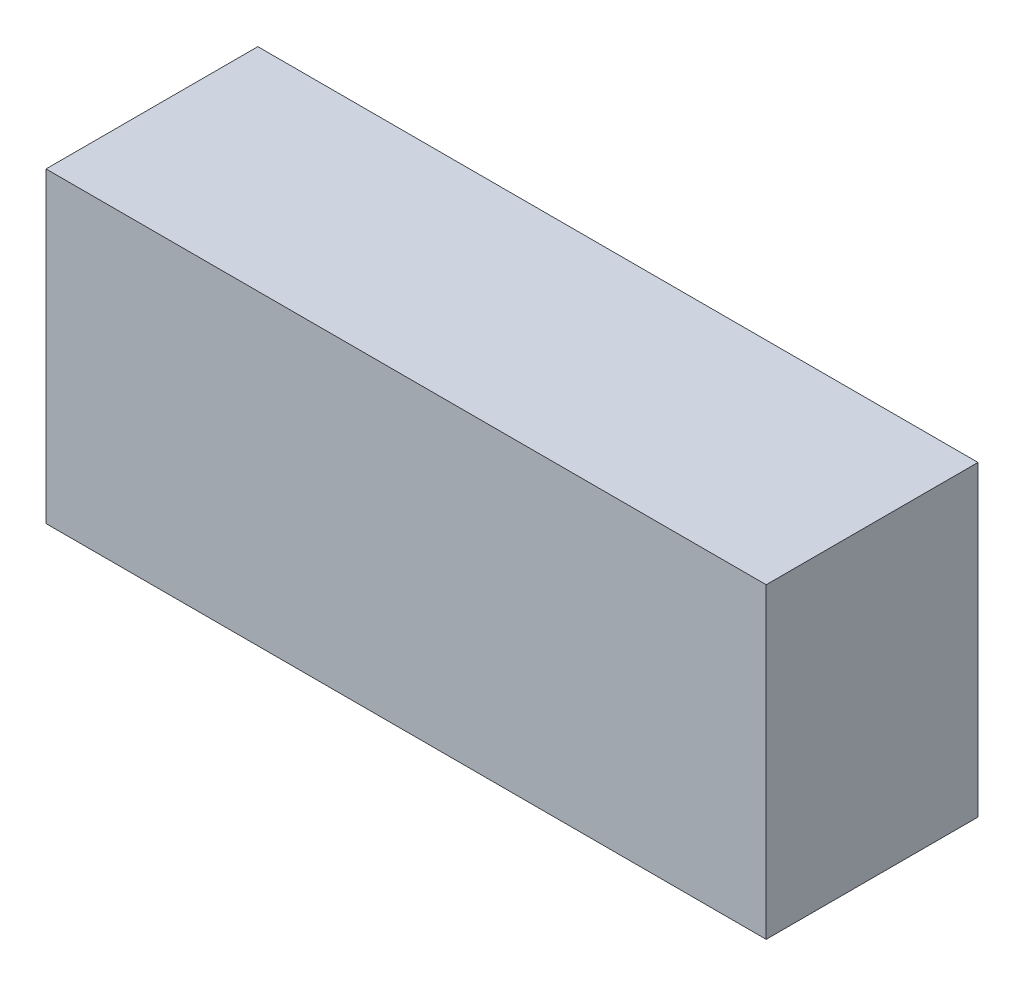
from build123d import *

# Parameters (mm, degrees)
CROQUIS1_W              = 68
CROQUIS1_H              = 29
SALIENTE_EXTRUIR1_DEPTH = 20


with BuildPart() as part:
    # Croquis1 → Saliente-Extruir1 (new body)
    with BuildSketch(Plane.XY):
        with Locations((-4.350133521, 15.452702703)):
            Rectangle(CROQUIS1_W, CROQUIS1_H)
    extrude(amount=SALIENTE_EXTRUIR1_DEPTH)


solid = part.part
